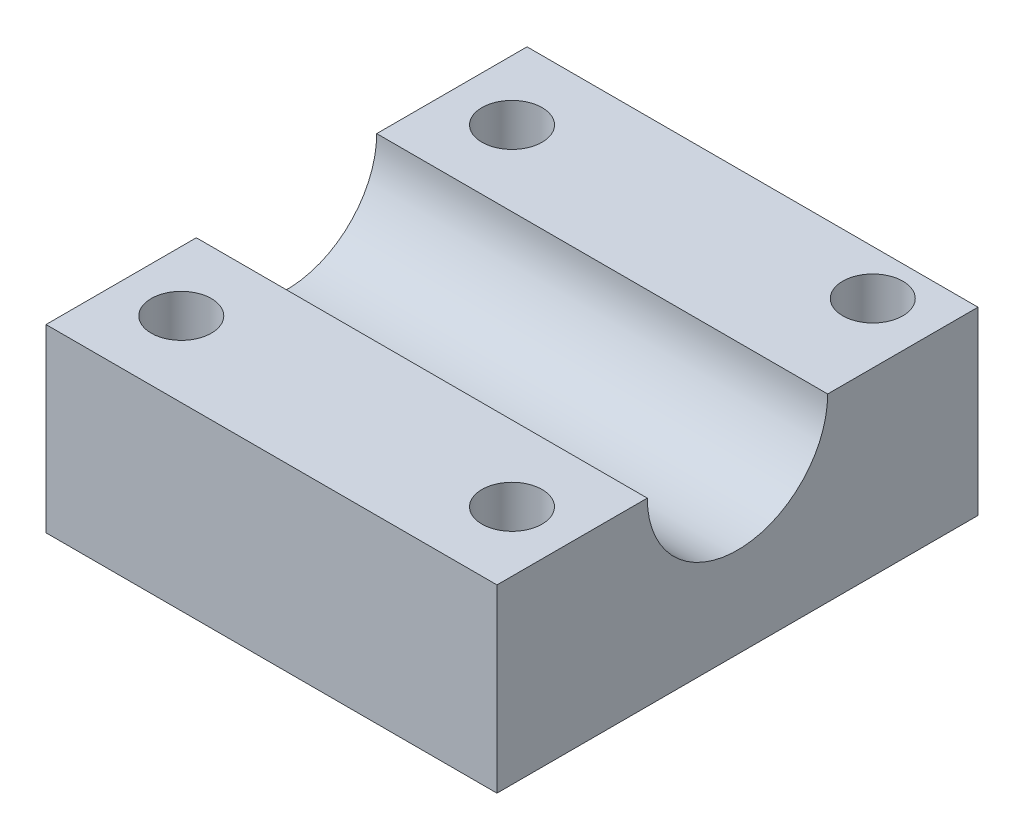
from build123d import *

# Parameters (mm, degrees)
BOSS_EXTRUDE1_DEPTH = 30
SKETCH2_R           = 2
CUT_EXTRUDE1_DEPTH  = 13


with BuildPart() as part:
    # Sketch1 → Boss-Extrude1 (new body)
    with BuildSketch(Plane(origin=(0, 0, 0), x_dir=(0, 0, -1), z_dir=(1, 0, 0))):
        with BuildLine():
            Line((0, 0), (0, 12))
            Line((0, 12), (10, 12))
            ThreePointArc((10, 12), (16, 6), (22, 12))
            Line((22, 12), (32, 12))
            Line((32, 12), (32, 0))
            Line((32, 0), (0, 0))
        make_face()
    extrude(amount=BOSS_EXTRUDE1_DEPTH)

    # Sketch2 → Cut-Extrude1 (cut, through all)
    with BuildSketch(Plane(origin=(0, 12, 0), x_dir=(1, 0, 0), z_dir=(0, 1, 0))):
        with Locations((4, 27)):
            Circle(SKETCH2_R)
        with Locations((26, 29)):
            Circle(SKETCH2_R)
        with Locations((4, 5)):
            Circle(SKETCH2_R)
        with Locations((26, 5)):
            Circle(SKETCH2_R)
    extrude(amount=-CUT_EXTRUDE1_DEPTH, mode=Mode.SUBTRACT)


solid = part.part
